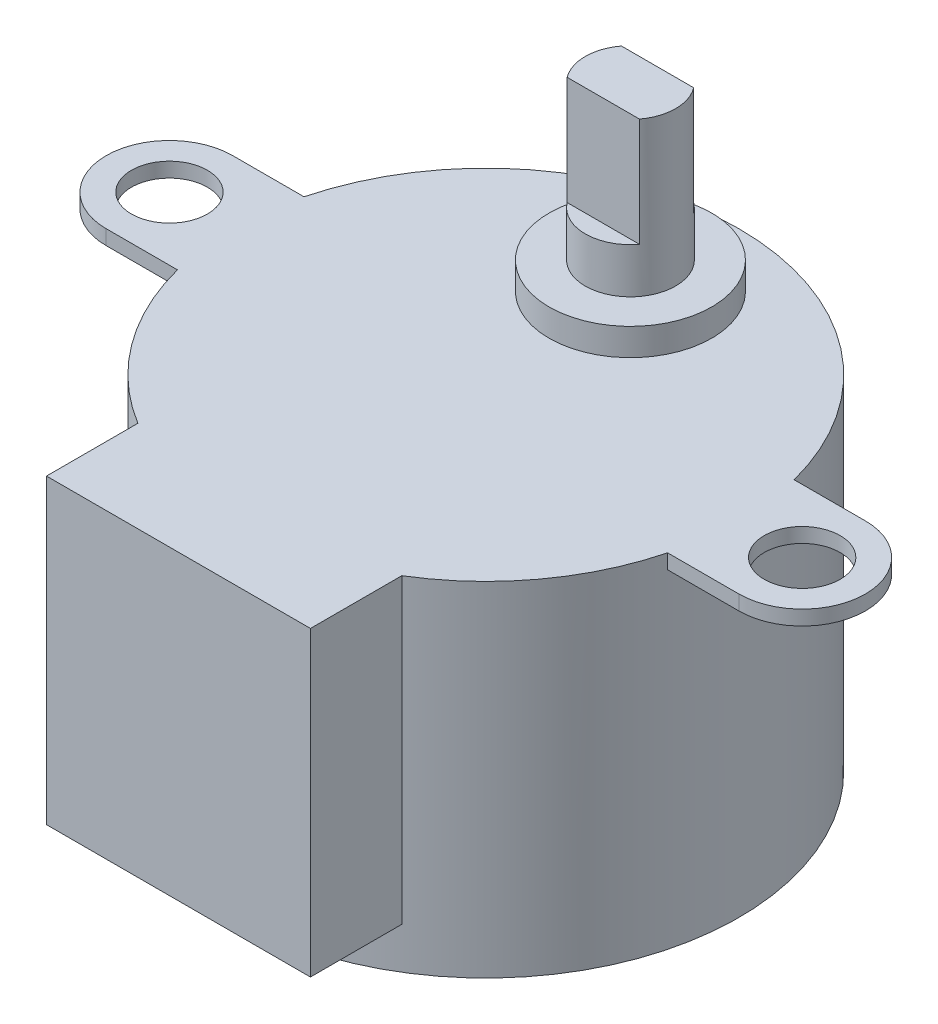
from build123d import *

# Parameters (mm, degrees)
SKETCH1_R           = 14
BOSS_EXTRUDE1_DEPTH = 19
BOSS_EXTRUDE2_DEPTH = 0.8128
SKETCH3_R           = 2.1
CUT_EXTRUDE1_DEPTH  = 0.8128
SKETCH4_R           = 4.5
BOSS_EXTRUDE3_DEPTH = 1.5
BOSS_EXTRUDE4_START = -1.5
SKETCH5_R           = 2.5
BOSS_EXTRUDE4_DEPTH = 10
CUT_EXTRUDE2_DEPTH  = 6
SKETCH7_W           = 14.6
SKETCH7_H           = 5.05387092
BOSS_EXTRUDE5_DEPTH = 16.7


with BuildPart() as part:
    # Sketch1 → Boss-Extrude1 (new body)
    with BuildSketch(Plane(origin=(0, 0, 0), x_dir=(1, 0, 0), z_dir=(0, 1, 0))):
        Circle(SKETCH1_R)
    extrude(amount=-BOSS_EXTRUDE1_DEPTH)

    # Sketch2 → Boss-Extrude2 (add)
    with BuildSketch(Plane(origin=(0, 0, 0), x_dir=(1, 0, 0), z_dir=(0, 1, 0))):
        with BuildLine():
            Line((-17.5, 3.5), (17.5, 3.5))
            ThreePointArc((17.5, 3.5), (21, 0), (17.5, -3.5))
            Line((17.5, -3.5), (-17.5, -3.5))
            ThreePointArc((-17.5, -3.5), (-21, 0), (-17.5, 3.5))
        make_face()
    extrude(amount=-BOSS_EXTRUDE2_DEPTH)

    # Sketch3 → Cut-Extrude1 (cut)
    with BuildSketch(Plane(origin=(0, 0, 0), x_dir=(1, 0, 0), z_dir=(0, 1, 0))):
        with Locations((-17.5, 0)):
            Circle(SKETCH3_R)
        with Locations((17.5, 0)):
            Circle(SKETCH3_R)
    extrude(amount=-CUT_EXTRUDE1_DEPTH, mode=Mode.SUBTRACT)

    # Sketch4 → Boss-Extrude3 (add)
    with BuildSketch(Plane(origin=(0, 0, 0), x_dir=(1, 0, 0), z_dir=(0, 1, 0))):
        with Locations((0, 8)):
            Circle(SKETCH4_R)
    extrude(amount=BOSS_EXTRUDE3_DEPTH)

    # Sketch5 → Boss-Extrude4 (add)
    with BuildSketch(Plane(origin=(0, 1.5, 0), x_dir=(1, 0, 0), z_dir=(0, 1, 0)).offset(BOSS_EXTRUDE4_START)):
        with Locations((0, 8)):
            Circle(SKETCH5_R)
    extrude(amount=BOSS_EXTRUDE4_DEPTH)

    # Sketch6 → Cut-Extrude2 (cut)
    with BuildSketch(Plane(origin=(0, 10, 0), x_dir=(1, 0, 0), z_dir=(0, 1, 0))):
        with BuildLine():
            ThreePointArc((2, 9.5), (0, 10.5), (-2, 9.5))
            Line((-2, 9.5), (2, 9.5))
        make_face()
        with BuildLine():
            Line((2, 6.5), (-2, 6.5))
            ThreePointArc((-2, 6.5), (0, 5.5), (2, 6.5))
        make_face()
    extrude(amount=-CUT_EXTRUDE2_DEPTH, mode=Mode.SUBTRACT)

    # Sketch7 → Boss-Extrude5 (add)
    with BuildSketch(Plane(origin=(0, 0, 0), x_dir=(1, 0, 0), z_dir=(0, 1, 0))):
        with Locations((0, -14.47306454)):
            Rectangle(SKETCH7_W, SKETCH7_H)
    extrude(amount=-BOSS_EXTRUDE5_DEPTH)


solid = part.part
